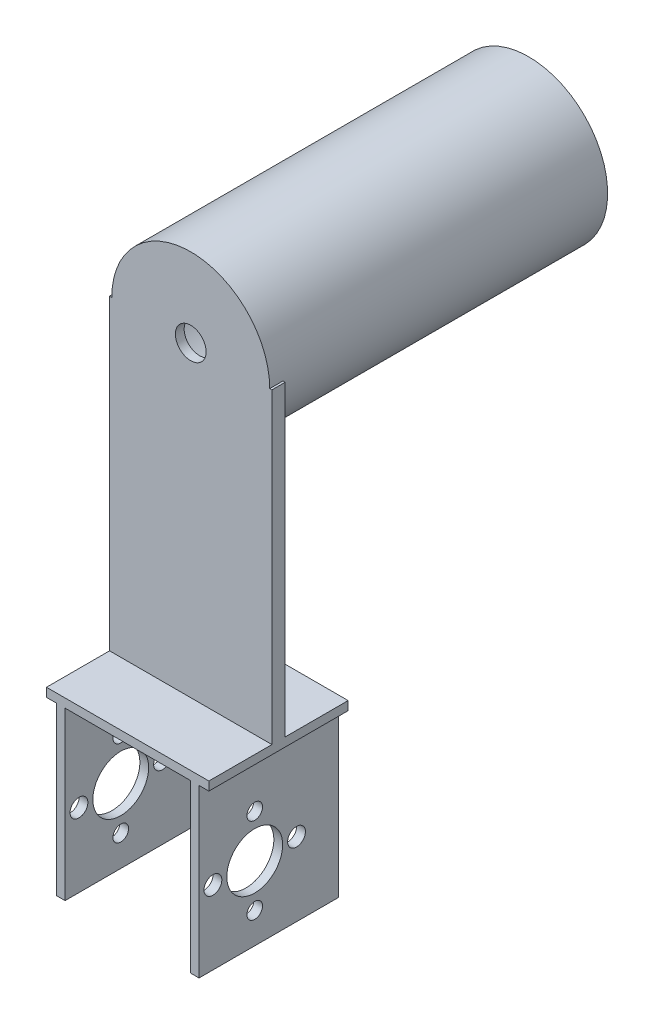
from build123d import *

# Parameters (mm, degrees)
SKETCH1_W                = 2
SKETCH1_H                = 31.74
BOSS_EXTRUDE1_DEPTH      = 40
BOSS_EXTRUDE1_2_DEPTH    = 40
SKETCH2_W                = 37
SKETCH2_H                = 31.74
BOSS_EXTRUDE3_DEPTH      = 2
SKETCH8_W                = 37
SKETCH8_H                = 3
BOSS_EXTRUDE4_DEPTH      = 70
SKETCH12_R               = 18
BOSS_EXTRUDE6_DEPTH      = 74
BOSS_EXTRUDE6_DEPTH_BACK = 3
SKETCH18_R               = 16.1
CUT_EXTRUDE2_DEPTH       = 75
SKETCH19_R               = 3.5
CUT_EXTRUDE3_DEPTH       = 74
SKETCH20_R               = 6.36
SKETCH20_R_2             = 1.78
SKETCH20_R_3             = 2.03
CUT_EXTRUDE4_DEPTH       = 3.24
CUT_EXTRUDE4_DEPTH_BACK  = 35.76


with BuildPart() as part:
    # Sketch1 → Boss-Extrude1 (new body)
    with BuildSketch(Plane(origin=(0, 0, 0), x_dir=(1, 0, 0), z_dir=(0, 1, 0))):
        with Locations((-2.074327578, -14.662349727)):
            Rectangle(SKETCH1_W, SKETCH1_H)
    extrude(amount=BOSS_EXTRUDE1_DEPTH)



with BuildPart() as body_2:
    # Sketch1 → Boss-Extrude1 2 (new body)
    with BuildSketch(Plane(origin=(0, 0, 0), x_dir=(1, 0, 0), z_dir=(0, 1, 0))):
        with Locations((28.453672422, -14.662349727)):
            Rectangle(SKETCH1_W, SKETCH1_H)
    extrude(amount=BOSS_EXTRUDE1_2_DEPTH)


with BuildPart() as part_1:
    add(part.part)

    add(body_2.part)  # Boss-Extrude3 merges body 2
    # Sketch2 → Boss-Extrude3 (add)
    with BuildSketch(Plane(origin=(0, 40, 0), x_dir=(1, 0, 0), z_dir=(0, 1, 0))):
        with Locations((13.193672422, -14.662349727)):
            Rectangle(SKETCH2_W, SKETCH2_H)
    extrude(amount=-BOSS_EXTRUDE3_DEPTH)

    # Sketch8 → Boss-Extrude4 (add)
    with BuildSketch(Plane(origin=(0, 40, 0), x_dir=(1, 0, 0), z_dir=(0, 1, 0))):
        with Locations((13.193672422, -14.662349727)):
            Rectangle(SKETCH8_W, SKETCH8_H)
    extrude(amount=BOSS_EXTRUDE4_DEPTH)

    # Sketch12 → Boss-Extrude6 (add, two sides)
    with BuildSketch(Plane(origin=(0, 0, 13.162349727), x_dir=(-1, 0, 0), z_dir=(0, 0, -1))) as boss_extrude6_sk:
        with Locations((-13.193672422, 110)):
            Circle(SKETCH12_R)
    extrude(amount=BOSS_EXTRUDE6_DEPTH)
    extrude(boss_extrude6_sk.sketch, amount=-BOSS_EXTRUDE6_DEPTH_BACK)

    # Sketch18 → Cut-Extrude2 (cut)
    with BuildSketch(Plane(origin=(0, 0, -60.837650273), x_dir=(-1, 0, 0), z_dir=(0, 0, -1))):
        with Locations((-13.193672422, 110)):
            Circle(SKETCH18_R)
    extrude(amount=-CUT_EXTRUDE2_DEPTH, mode=Mode.SUBTRACT)

    # Sketch19 → Cut-Extrude3 (cut)
    with BuildSketch(Plane(origin=(0, 0, 14.162349727), x_dir=(-1, 0, 0), z_dir=(0, 0, -1))):
        with Locations((-13.193672422, 110)):
            Circle(SKETCH19_R)
    extrude(amount=-CUT_EXTRUDE3_DEPTH, mode=Mode.SUBTRACT)

    # Sketch20 → Cut-Extrude4 (cut, two sides)
    with BuildSketch(Plane(origin=(29.453672422, 0, 0), x_dir=(0, 0, -1), z_dir=(1, 0, 0))) as cut_extrude4_sk:
        with Locations((-17.842349727, 16.779878139)):
            Circle(SKETCH20_R)
        with Locations((-17.842349727, 26.558878139)):
            Circle(SKETCH20_R_2)
        with Locations((-17.842349727, 7.000878139)):
            Circle(SKETCH20_R_2)
        with Locations((-27.367349727, 16.779878139)):
            Circle(SKETCH20_R_3)
        with Locations((-8.317349727, 16.779878139)):
            Circle(SKETCH20_R_3)
    extrude(amount=CUT_EXTRUDE4_DEPTH, mode=Mode.SUBTRACT)
    extrude(cut_extrude4_sk.sketch, amount=-CUT_EXTRUDE4_DEPTH_BACK, mode=Mode.SUBTRACT)


solid = part_1.part
